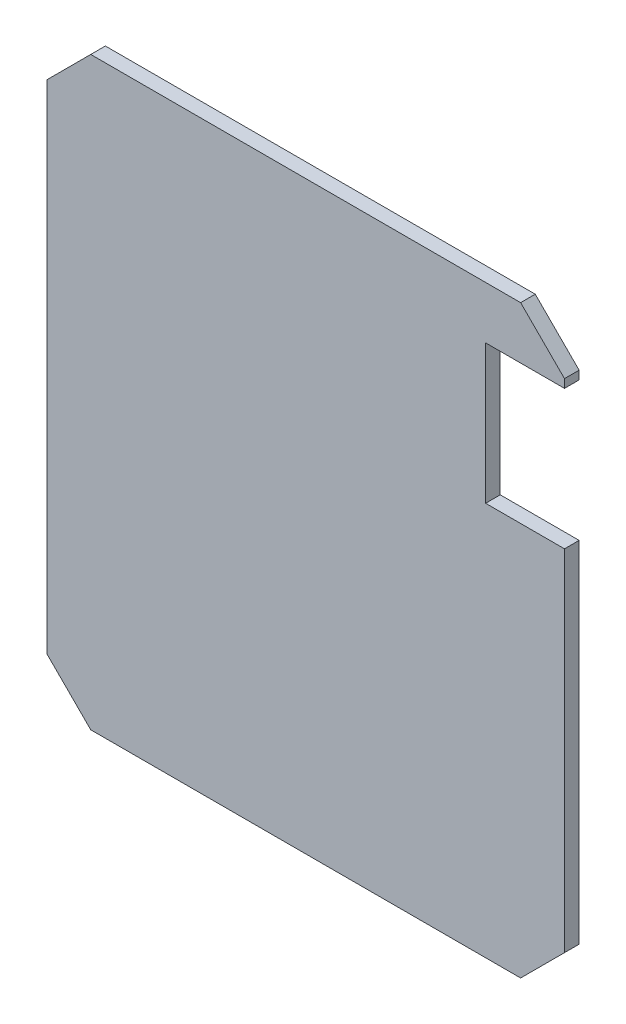
from build123d import *

# Parameters (mm, degrees)
EXTRUDE_1_DEPTH     = 1
SKETCH_2_W          = 5.394183388
SKETCH_2_H          = 9.500952502
CUT_EXTRUDE_1_DEPTH = 2


with BuildPart() as part:
    # 草图1 → 凸台-拉伸1 (new body)
    with BuildSketch(Plane.XY):
        Polygon((14.7, -20), (-14.7, -20), (-17.7, -17), (-17.7, 17), (-14.7, 20), (14.7, 20), (17.7, 17), (17.7, -17), align=None)
    extrude(amount=EXTRUDE_1_DEPTH)

    # 草图2 → 切除-拉伸1 (cut, through all)
    with BuildSketch(Plane.XY.offset(1)):
        with Locations((15.002908306, 11.67014351)):
            Rectangle(SKETCH_2_W, SKETCH_2_H)
    extrude(amount=-CUT_EXTRUDE_1_DEPTH, mode=Mode.SUBTRACT)


solid = part.part
